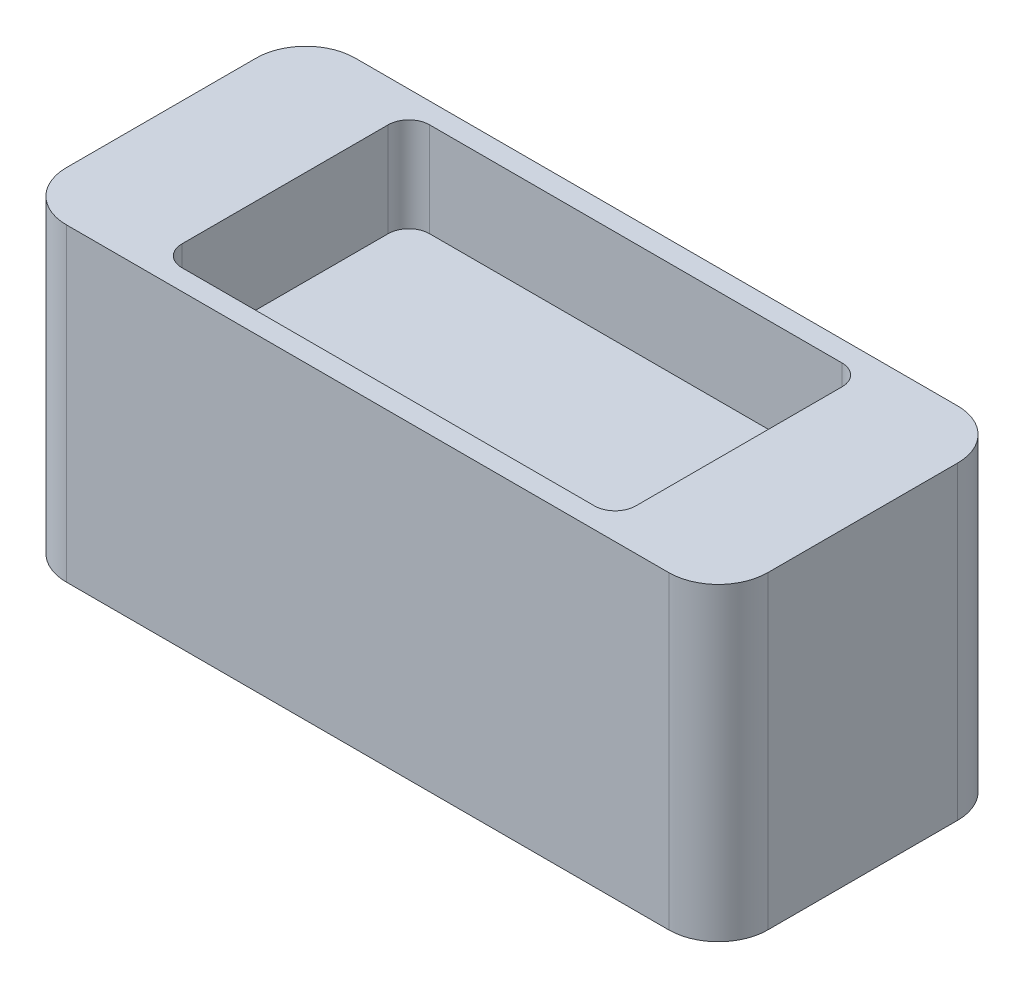
from build123d import *

# Parameters (mm, degrees)
BOSS_EXTRUDE1_DEPTH = 750
SKETCH1_3_W         = 1100
SKETCH1_3_H         = 600
CUT_EXTRUDE1_DEPTH  = 228.6
FILLET1_R           = 50.000000076


with BuildPart() as part:
    # Sketch1 → Boss-Extrude1 (new body)
    with BuildSketch(Plane(origin=(0, 0, 0), x_dir=(1, 0, 0), z_dir=(0, 1, 0))):
        with BuildLine():
            Line((730, 350), (-730, 350))
            ThreePointArc((-730, 350), (-814.852813742, 314.852813742), (-850, 230))
            Line((-850, 230), (-850, -230))
            ThreePointArc((-850, -230), (-814.852813742, -314.852813742), (-730, -350))
            Line((-730, -350), (730, -350))
            ThreePointArc((730, -350), (814.852813742, -314.852813742), (850, -230))
            Line((850, -230), (850, 230))
            ThreePointArc((850, 230), (814.852813742, 314.852813742), (730, 350))
        make_face()
    extrude(amount=-BOSS_EXTRUDE1_DEPTH)

    # Sketch1_3 → Cut-Extrude1 (cut)
    with BuildSketch(Plane(origin=(0, 0, 0), x_dir=(1, 0, 0), z_dir=(0, 1, 0))):
        Rectangle(SKETCH1_3_W, SKETCH1_3_H)
    extrude(amount=-CUT_EXTRUDE1_DEPTH, mode=Mode.SUBTRACT)

    # Fillet1
    fillet1_edges = [part.edges().sort_by_distance(p)[0] for p in [
        (550, -114.3, 300),
        (-550, -114.3, 300),
        (550, -114.3, -300),
        (-550, -114.3, -300),
    ]]
    fillet(fillet1_edges, radius=FILLET1_R)


solid = part.part
